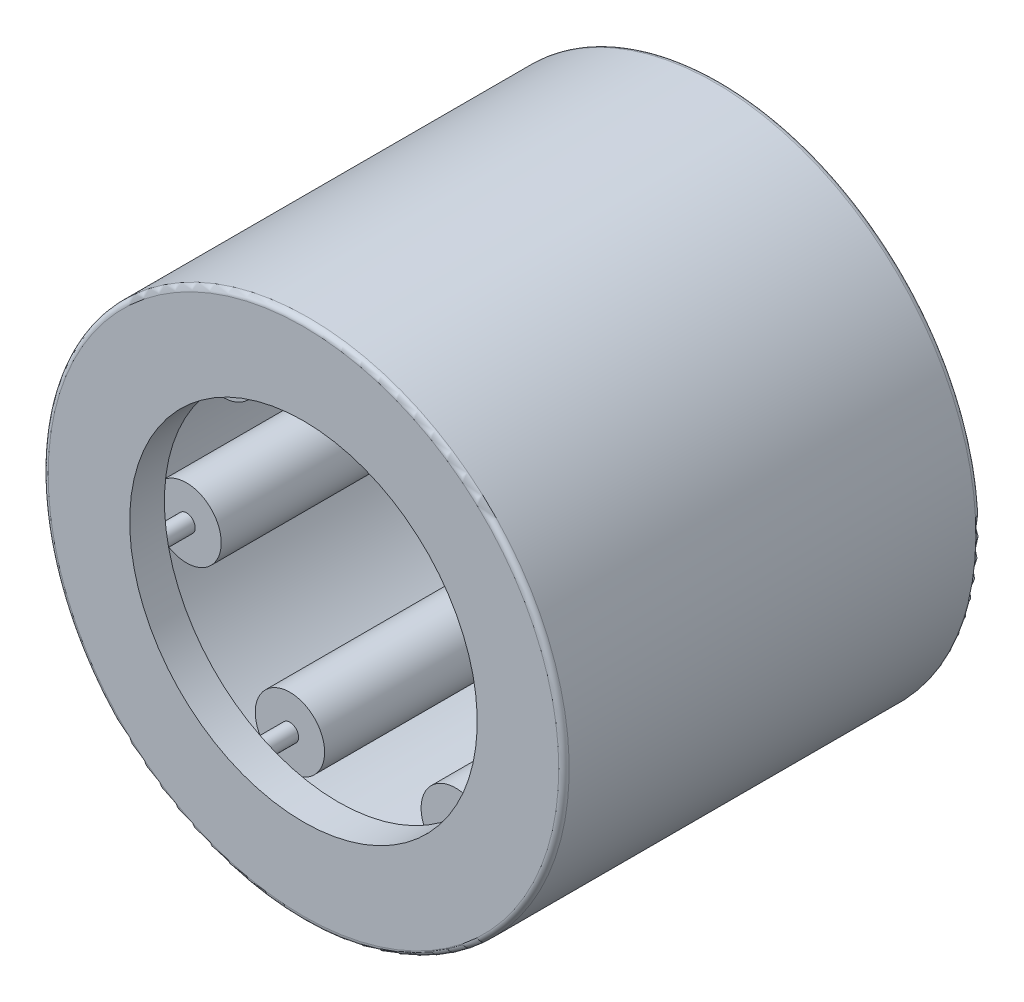
from build123d import *

# Parameters (mm, degrees)
SKETCH2_W         = 5.338
SKETCH2_H         = 0.499125
SKETCH3_W         = 6.669
SKETCH3_H         = 0.166375
CIRPATTERN1_COUNT = 7
CIRPATTERN1_ANGLE = 308.571428571
FILLET1_R         = 0.09993


with BuildPart() as part:
    # Sketch1 → Revolve1 (revolve)
    with BuildSketch(Plane(origin=(0, 0, 0), x_dir=(0, 0, -1), z_dir=(1, 0, 0))):
        Polygon((-4, 4.9965), (4, 4.9965), (4, 3.33275), (3.3345, 3.33275), (3.3345, 4.331), (-3.3345, 4.331), (-3.3345, 3.33275), (-4, 3.33275), align=None)
    revolve(axis=Axis((0, 0, 4), (0, 0, -1)))

    # Fillet1
    fillet1_edges = [part.edges().sort_by_distance(p)[0] for p in [
        (0, -4.9965, 4),
        (0, -4.9965, -4),
    ]]
    fillet(fillet1_edges, radius=FILLET1_R)


with BuildPart() as body_2:
    # Sketch2 → Revolve2 (revolve)
    with BuildSketch(Plane(origin=(0, 0, 0), x_dir=(0, 0, -1), z_dir=(1, 0, 0))):
        with Locations((0, 4.0814375)):
            Rectangle(SKETCH2_W, SKETCH2_H)
    revolve(axis=Axis((0, 3.6655, 2.669), (0, 0, -1)))


with BuildPart() as body_3:
    # Sketch3 → Revolve3 (revolve)
    with BuildSketch(Plane(origin=(0, 0, 0), x_dir=(0, 0, -1), z_dir=(1, 0, 0))):
        with Locations((0, 3.7486875)):
            Rectangle(SKETCH3_W, SKETCH3_H)
    revolve(axis=Axis((0, 3.6655, 3.3345), (0, 0, -1)))


with BuildPart() as cirpattern1_1:
    # CirPattern1: pattern copy
    add(body_3.part.rotate(Axis((0, 0, -4), (0, 0, 1)), 1 * CIRPATTERN1_ANGLE / (CIRPATTERN1_COUNT - 1)))


with BuildPart() as cirpattern1_2:
    # CirPattern1: pattern copy
    add(body_3.part.rotate(Axis((0, 0, -4), (0, 0, 1)), 2 * CIRPATTERN1_ANGLE / (CIRPATTERN1_COUNT - 1)))


with BuildPart() as cirpattern1_3:
    # CirPattern1: pattern copy
    add(body_3.part.rotate(Axis((0, 0, -4), (0, 0, 1)), 3 * CIRPATTERN1_ANGLE / (CIRPATTERN1_COUNT - 1)))


with BuildPart() as cirpattern1_4:
    # CirPattern1: pattern copy
    add(body_3.part.rotate(Axis((0, 0, -4), (0, 0, 1)), 4 * CIRPATTERN1_ANGLE / (CIRPATTERN1_COUNT - 1)))


with BuildPart() as cirpattern1_5:
    # CirPattern1: pattern copy
    add(body_3.part.rotate(Axis((0, 0, -4), (0, 0, 1)), 5 * CIRPATTERN1_ANGLE / (CIRPATTERN1_COUNT - 1)))


with BuildPart() as cirpattern1_6:
    # CirPattern1: pattern copy
    add(body_3.part.rotate(Axis((0, 0, -4), (0, 0, 1)), 6 * CIRPATTERN1_ANGLE / (CIRPATTERN1_COUNT - 1)))


with BuildPart() as cirpattern1_7:
    # CirPattern1: pattern copy
    add(body_2.part.rotate(Axis((0, 0, -4), (0, 0, 1)), 1 * CIRPATTERN1_ANGLE / (CIRPATTERN1_COUNT - 1)))


with BuildPart() as cirpattern1_8:
    # CirPattern1: pattern copy
    add(body_2.part.rotate(Axis((0, 0, -4), (0, 0, 1)), 2 * CIRPATTERN1_ANGLE / (CIRPATTERN1_COUNT - 1)))


with BuildPart() as cirpattern1_9:
    # CirPattern1: pattern copy
    add(body_2.part.rotate(Axis((0, 0, -4), (0, 0, 1)), 3 * CIRPATTERN1_ANGLE / (CIRPATTERN1_COUNT - 1)))


with BuildPart() as cirpattern1_10:
    # CirPattern1: pattern copy
    add(body_2.part.rotate(Axis((0, 0, -4), (0, 0, 1)), 4 * CIRPATTERN1_ANGLE / (CIRPATTERN1_COUNT - 1)))


with BuildPart() as cirpattern1_11:
    # CirPattern1: pattern copy
    add(body_2.part.rotate(Axis((0, 0, -4), (0, 0, 1)), 5 * CIRPATTERN1_ANGLE / (CIRPATTERN1_COUNT - 1)))


with BuildPart() as cirpattern1_12:
    # CirPattern1: pattern copy
    add(body_2.part.rotate(Axis((0, 0, -4), (0, 0, 1)), 6 * CIRPATTERN1_ANGLE / (CIRPATTERN1_COUNT - 1)))


solid = Compound([part.part, body_2.part, body_3.part, cirpattern1_1.part, cirpattern1_2.part, cirpattern1_3.part, cirpattern1_4.part, cirpattern1_5.part, cirpattern1_6.part, cirpattern1_7.part, cirpattern1_8.part, cirpattern1_9.part, cirpattern1_10.part, cirpattern1_11.part, cirpattern1_12.part])
